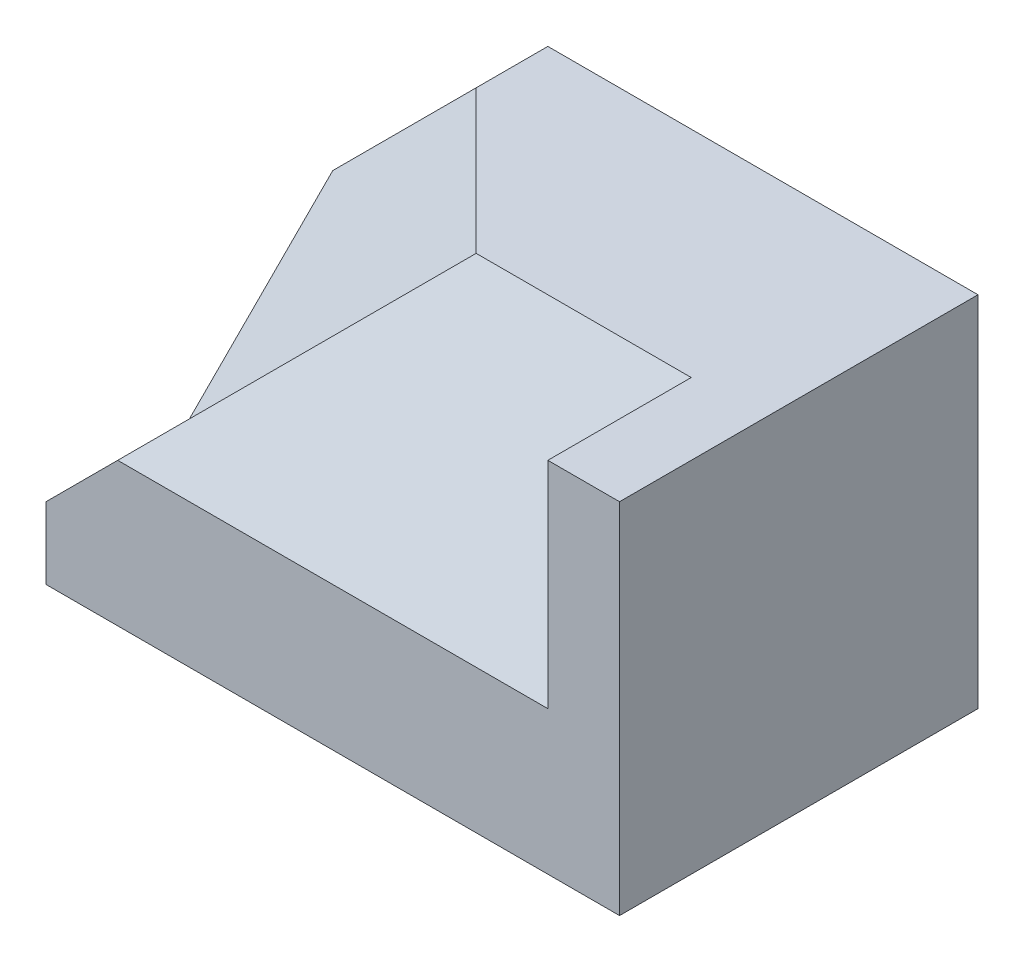
from build123d import *

# Parameters (mm, degrees)
BOSS_EXTRUDE1_DEPTH = 3
CUT_EXTRUDE2_DEPTH  = 1
BOSS_EXTRUDE2_DEPTH = 2
BOSS_EXTRUDE3_DEPTH = 2
CUT_EXTRUDE3_DEPTH  = 3


with BuildPart() as part:
    # Sketch1 → Boss-Extrude1 (new body)
    with BuildSketch(Plane.XY):
        Polygon((-4, 0.5), (-2, 2.5), (4, 2.5), (4, -2.5), (-4, -2.5), align=None)
    extrude(amount=BOSS_EXTRUDE1_DEPTH)

    # 3DSketch1 → Cut-Extrude2 (cut, along a direction that is not the sketch's normal)
    with BuildSketch(Plane(origin=(-4, -1.5, 3), x_dir=(0.7071067811865476, 0.7071067811865476, 0), z_dir=(-0.5773502691896258, 0.5773502691896258, 0.5773502691896258))):
        Polygon((0, 0), (1.414213562, 2.449489743), (4.242640687, 2.449489743), (5.656854249, 0), align=None)
    extrude(amount=CUT_EXTRUDE2_DEPTH, dir=(-0.7071067811865476, 0.7071067811865476, 0), mode=Mode.SUBTRACT)


with BuildPart() as cut_extrude2_kept_piece:
    # of the separate pieces the step leaves, the one the design keeps (cut_extrude2_pieces_kept)
    add(part.part.solids().sort_by_distance((-4, 0.5, 0))[0])

    # Sketch2 → Boss-Extrude2 (add)
    with BuildSketch(Plane.XY.offset(3)):
        Polygon((4, 2.5), (3, 2.5), (3, -0.5), (-3, -0.5), (-4, -1.5), (-4, -2.5), (4, -2.5), align=None)
    extrude(amount=BOSS_EXTRUDE2_DEPTH)

    # Sketch3 → Boss-Extrude3 (add)
    with BuildSketch(Plane.XY.offset(3)):
        Polygon((-3, -0.5), (3, -0.5), (3, 2.5), (0, 2.5), align=None)
    extrude(amount=BOSS_EXTRUDE3_DEPTH)

    # 3DSketch3 → Cut-Extrude3 (cut, along a direction that is not the sketch's normal)
    with BuildSketch(Plane(origin=(-4, -0.5, 5), x_dir=(0.8890008890013336, 0.38100038100057165, -0.25400025400038106), z_dir=(0, -0.5547001962252291, -0.8320502943378437))):
        Polygon((0, 0), (5.207005207, -1.37371641), (7.874007874, 0), (6.223006223, 3.205338289), align=None)
    extrude(amount=-CUT_EXTRUDE3_DEPTH, dir=(0, -1, 0), mode=Mode.SUBTRACT)


solid = cut_extrude2_kept_piece.part
